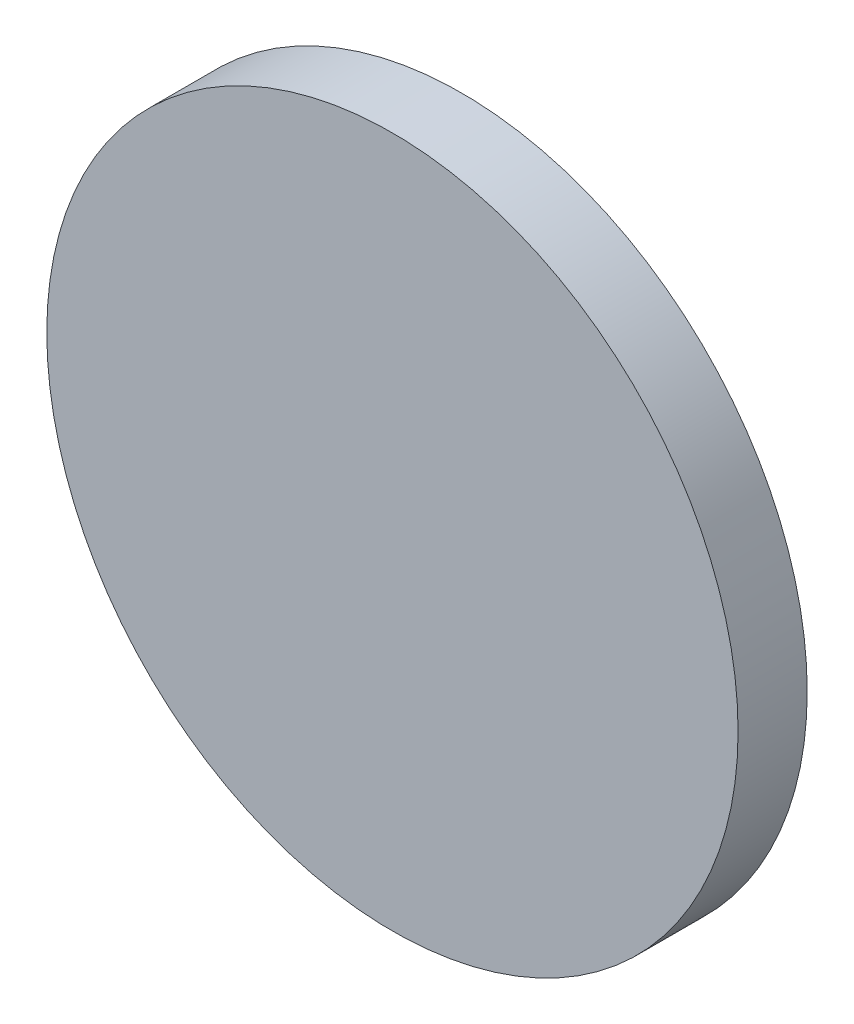
from build123d import *

# Parameters (mm, degrees)
SKETCH_1_R      = 10
EXTRUDE_1_DEPTH = 2


with BuildPart() as part:
    # 草图1 → 凸台-拉伸1 (new body)
    with BuildSketch(Plane.XY):
        Circle(SKETCH_1_R)
    extrude(amount=EXTRUDE_1_DEPTH)


solid = part.part
